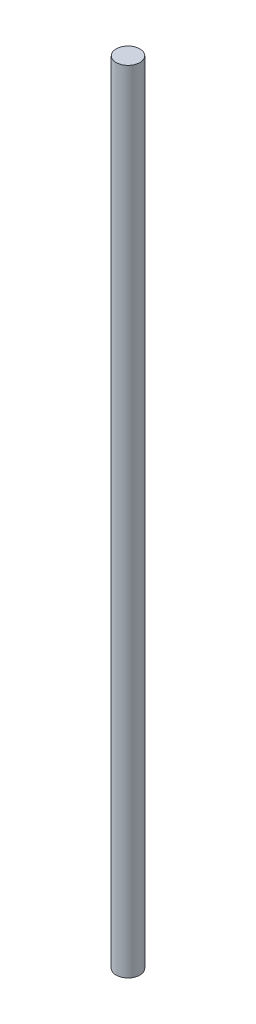
from build123d import *

# Parameters (mm, degrees)
SKETCH1_R           = 2.286
BOSS_EXTRUDE1_DEPTH = 152.4


with BuildPart() as part:
    # Sketch1 → Boss-Extrude1 (new body)
    with BuildSketch(Plane(origin=(0, 0, 0), x_dir=(1, 0, 0), z_dir=(0, 1, 0))):
        Circle(SKETCH1_R)
    extrude(amount=BOSS_EXTRUDE1_DEPTH)


solid = part.part
